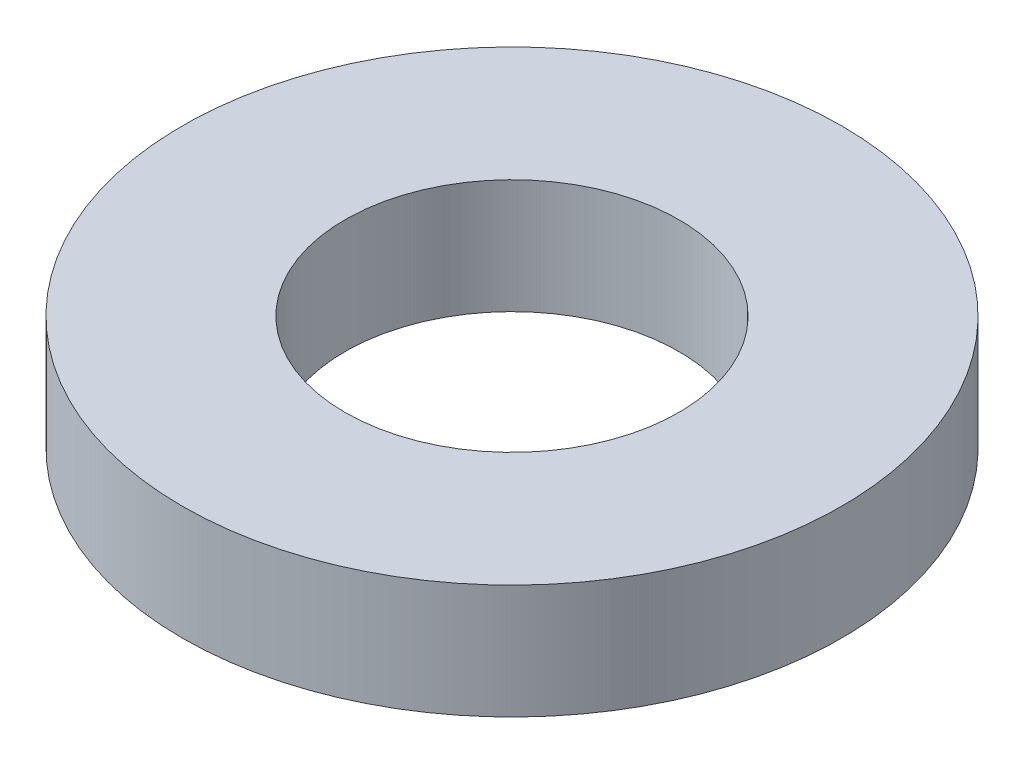
from build123d import *

# Parameters (mm, degrees)
SKETCH1_R           = 4.7625
SKETCH1_R_2         = 2.413
BOSS_EXTRUDE1_DEPTH = 1.651


with BuildPart() as part:
    # Sketch1 → Boss-Extrude1 (new body)
    with BuildSketch(Plane(origin=(0, 0, 0), x_dir=(1, 0, 0), z_dir=(0, 1, 0))):
        Circle(SKETCH1_R)
        Circle(SKETCH1_R_2, mode=Mode.SUBTRACT)
    extrude(amount=BOSS_EXTRUDE1_DEPTH)


solid = part.part
